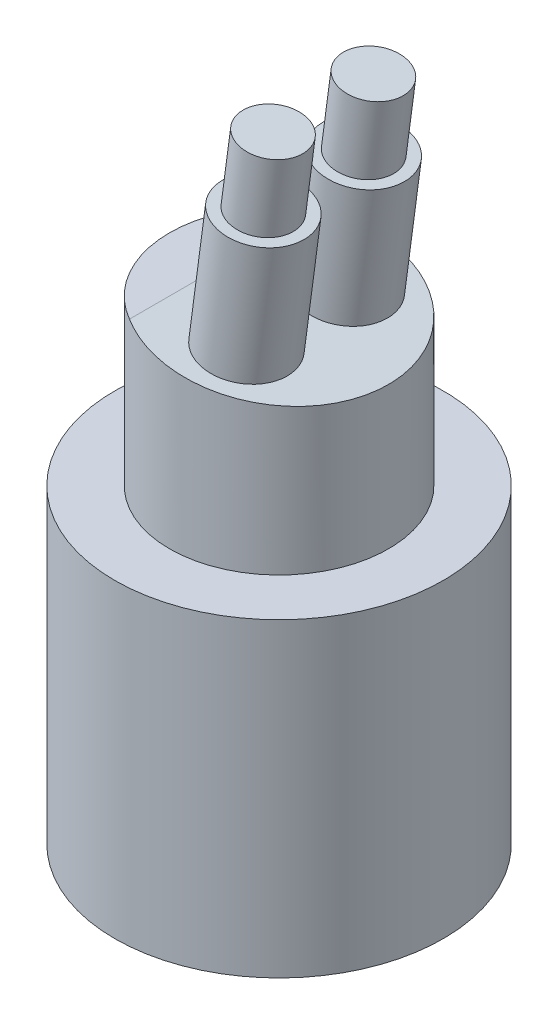
from build123d import *

# Parameters (mm, degrees)
SKETCH1_R           = 9
BOSS_EXTRUDE1_DEPTH = 17
SKETCH2_R           = 6
BOSS_EXTRUDE2_DEPTH = 9
CUT_EXTRUDE1_DEPTH  = 8.5
SKETCH4_R           = 2.25
BOSS_EXTRUDE3_DEPTH = 11
SKETCH5_R           = 2.25
SKETCH5_R_2         = 1.65
CUT_EXTRUDE2_DEPTH  = 4
SKETCH6_R           = 2.05
CUT_EXTRUDE3_DEPTH  = 5


with BuildPart() as part:
    # Sketch1 → Boss-Extrude1 (new body)
    with BuildSketch(Plane(origin=(0, 0, 0), x_dir=(1, 0, 0), z_dir=(0, 1, 0))):
        Circle(SKETCH1_R)
    extrude(amount=BOSS_EXTRUDE1_DEPTH)

    # Sketch2 → Boss-Extrude2 (add)
    with BuildSketch(Plane(origin=(0, 17, 0), x_dir=(1, 0, 0), z_dir=(0, 1, 0))):
        Circle(SKETCH2_R)
    extrude(amount=BOSS_EXTRUDE2_DEPTH)

    # Sketch3 → Cut-Extrude1 (cut, symmetric)
    with BuildSketch(Plane.XY):
        Polygon((-3, 26), (6, 26), (6, 24.8), align=None)
    extrude(amount=CUT_EXTRUDE1_DEPTH, both=True, mode=Mode.SUBTRACT)

    # Sketch4 → Boss-Extrude3 (add)
    with BuildSketch(Plane(origin=(3.35371179, 25.152838428, 0), x_dir=(0.991227901, -0.13216372, 0), z_dir=(0.13216372, 0.991227901, 0))):
        with Locations((-2.409940424, 2.75)):
            Circle(SKETCH4_R)
        with Locations((-2.409940424, -2.75)):
            Circle(SKETCH4_R)
    extrude(amount=BOSS_EXTRUDE3_DEPTH)

    # Sketch5 → Cut-Extrude2 (cut)
    with BuildSketch(Plane(origin=(4.807512711, 36.056345335, 0), x_dir=(0.991227901, -0.13216372, 0), z_dir=(0.13216372, 0.991227901, 0))):
        with Locations((-2.409940424, 2.75)):
            Circle(SKETCH5_R)
        with Locations((-2.409940424, 2.75)):
            Circle(SKETCH5_R_2, mode=Mode.SUBTRACT)
        with Locations((-2.409940424, -2.75)):
            Circle(SKETCH5_R)
        with Locations((-2.409940424, -2.75)):
            Circle(SKETCH5_R_2, mode=Mode.SUBTRACT)
    extrude(amount=-CUT_EXTRUDE2_DEPTH, mode=Mode.SUBTRACT)

    # Sketch6 → Cut-Extrude3 (cut)
    with BuildSketch(Plane.XZ):
        Circle(SKETCH6_R)
    extrude(amount=-CUT_EXTRUDE3_DEPTH, mode=Mode.SUBTRACT)


solid = part.part
